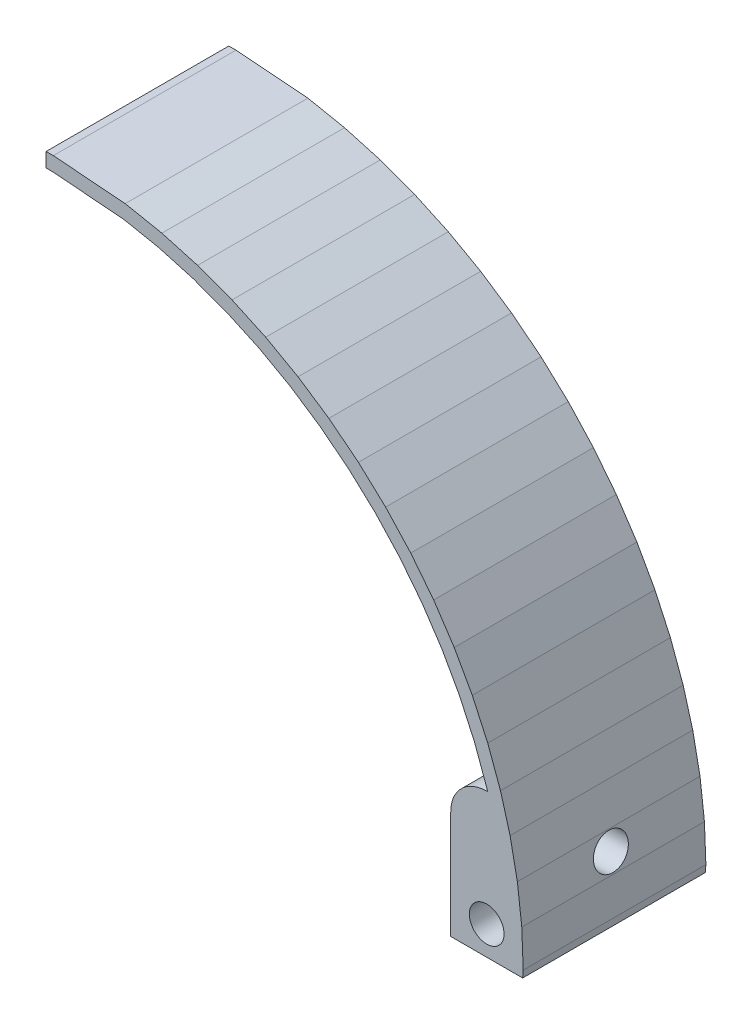
from build123d import *

# Parameters (mm, degrees)
BOSS_EXTRUDE1_DEPTH = 25.4
BOSS_EXTRUDE4_DEPTH = 25.4
SKETCH11_R          = 2.413
CUT_EXTRUDE5_DEPTH  = 10
SKETCH12_R          = 2.413
CUT_EXTRUDE6_DEPTH  = 67.32996137
CUT_EXTRUDE7_DEPTH  = 16.4


with BuildPart() as part:
    # Sketch2 → Boss-Extrude1 (new body)
    with BuildSketch(Plane.XY):
        Polygon((0, 0), (-0.197156462, 5), (-0.792344965, 10), (-1.773207125, 14.901444272), (-3.065228232, 19.490725009), (-4.786089298, 24.185257701), (-6.870037676, 28.727989265), (-9.305862968, 33.094493671), (-12.075009115, 37.252118227), (-15.162850216, 41.179727425), (-18.554323068, 44.856840338), (-22.220180921, 48.251699833), (-26.203519544, 51.392825818), (-30.362680664, 54.16796163), (-34.722984466, 56.605064941), (-39.261459458, 58.691934304), (-43.904843636, 60.400992103), (-48.717885048, 61.755478118), (-53.619641135, 62.726617227), (-63.5, 63.5), (-64.343927861, 63.5), (-64.343927861, 65.493901073), (-63.343927861, 65.493901073), (-53.346320006, 64.711340662), (-48.251922828, 63.702035375), (-43.287590163, 62.304972979), (-38.497110063, 60.541774617), (-33.81592061, 58.389282674), (-29.318144049, 55.875341756), (-25.027437614, 53.01243437), (-20.919464687, 49.773025992), (-17.137579866, 46.270716817), (-13.639271322, 42.477770187), (-10.454072963, 38.42632649), (-7.597619105, 34.137617236), (-5.085040747, 29.633523897), (-2.935391785, 24.947573759), (-1.160924955, 20.106803802), (0.172809103, 15.369357963), (1.184287688, 10.31492104), (1.798173514, 5.157850442), (1.998446984, 0.078801347), (1.920765751, -0.913615973), (0, -0.913615973), align=None)
    extrude(amount=BOSS_EXTRUDE1_DEPTH)

    # Sketch10 → Boss-Extrude4 (add, through all)
    with BuildSketch(Plane.XY.offset(25.4)):
        with BuildLine():
            Line((1.920765751, -0.913615973), (1.998446984, 0.078801347))
            Line((1.998446984, 0.078801347), (1.798173514, 5.157850442))
            Line((1.798173514, 5.157850442), (0.172809103, 15.369357963))
            Line((0.172809103, 15.369357963), (-0.873645975, 19.086384027))
            Line((-0.873645975, 19.086384027), (-3.079234249, 19.086384027))
            ThreePointArc((-3.079234249, 19.086384027), (-6.614768155, 17.621917933), (-8.079234249, 14.086384027))
            Line((-8.079234249, 14.086384027), (-8.079234249, -0.913615973))
            Line((-8.079234249, -0.913615973), (1.920765751, -0.913615973))
        make_face()
    extrude(amount=-BOSS_EXTRUDE4_DEPTH)

    # Sketch11 → Cut-Extrude5 (cut)
    with BuildSketch(Plane.XY.offset(25.4)):
        with Locations((-3.079234249, 3.086384027)):
            Circle(SKETCH11_R)
    cut_extrude5 = extrude(amount=-CUT_EXTRUDE5_DEPTH, mode=Mode.SUBTRACT)

    # Sketch12 → Cut-Extrude6 (cut, through all)
    with BuildSketch(Plane(origin=(1.998446984, 0.078801347, 0), x_dir=(0, 0, -1), z_dir=(0.999223492, 0.039400674, 0))):
        with Locations((-12.7, 7.7)):
            Circle(SKETCH12_R)
    extrude(amount=-CUT_EXTRUDE6_DEPTH, mode=Mode.SUBTRACT)

    # Mirror3: Cut-Extrude5 across plane
    add(cut_extrude5.mirror(Plane(origin=(0, 0, 12.7), x_dir=(1, 0, 0), z_dir=(0, 0, -1))), mode=Mode.SUBTRACT)

    # Sketch15 → Cut-Extrude7 (cut, through all)
    with BuildSketch(Plane(origin=(0, 0, 10), x_dir=(-1, 0, 0), z_dir=(0, 0, -1))):
        Polygon((4.48781187, 1.660586836), (4.50503144, 4.494961648), (1.670656628, 4.512181219), (1.653437058, 1.677806407), align=None)
    extrude(amount=-CUT_EXTRUDE7_DEPTH, mode=Mode.SUBTRACT)


solid = part.part
